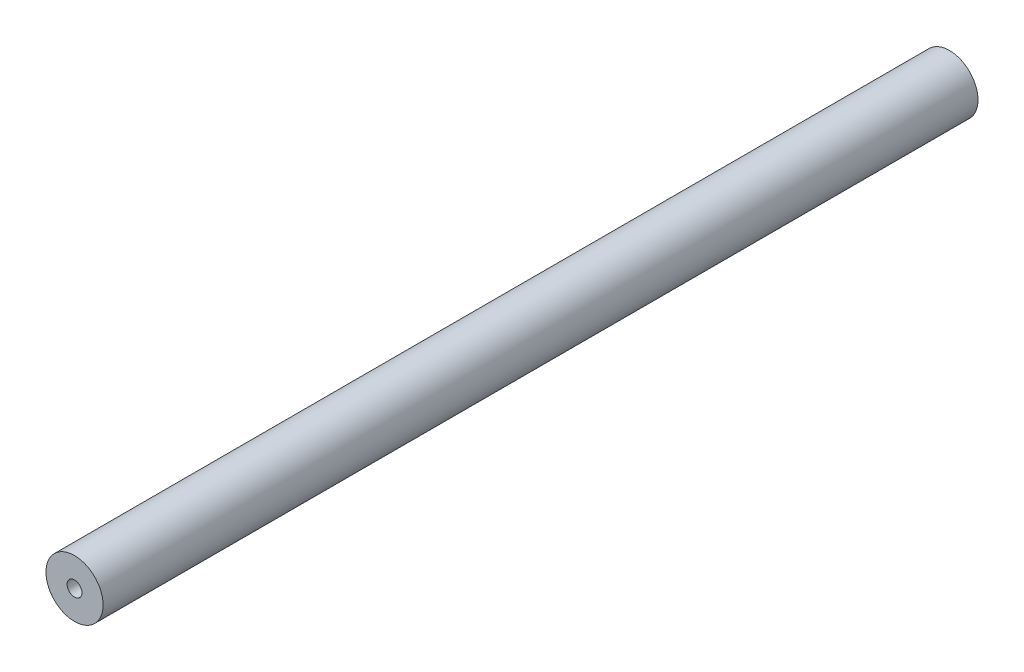
from build123d import *

# Parameters (mm, degrees)
SKETCH1_R           = 15.24
SKETCH1_R_2         = 3.96875
BOSS_EXTRUDE1_DEPTH = 233.3625


with BuildPart() as part:
    # Sketch1 → Boss-Extrude1 (new body, symmetric)
    with BuildSketch(Plane.XY):
        Circle(SKETCH1_R)
        Circle(SKETCH1_R_2, mode=Mode.SUBTRACT)
    extrude(amount=BOSS_EXTRUDE1_DEPTH, both=True)


solid = part.part
